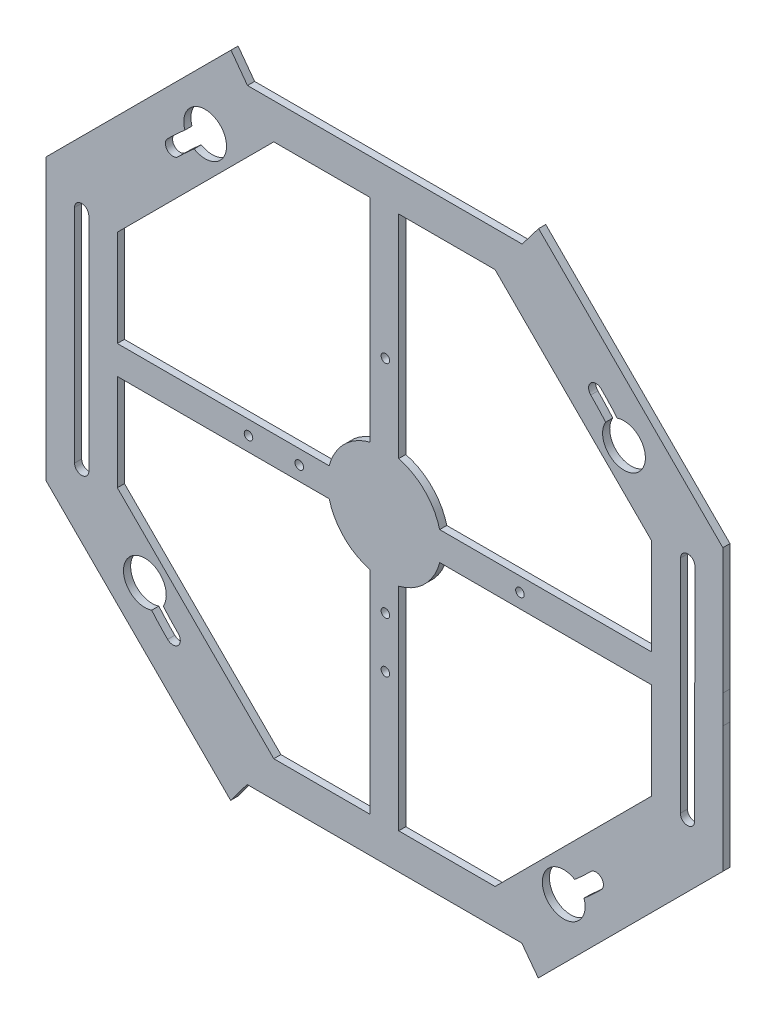
from build123d import *

# Parameters (mm, degrees)
BOSS_EXTRUDE1_DEPTH       = 3.175
SKETCH2_R                 = 3.302
BOSS_EXTRUDE2_DEPTH       = 3.175
BOSS_EXTRUDE3_DEPTH       = 3.175
BOSS_EXTRUDE4_DEPTH       = 3.175
SKETCH10_R                = 3.302
CUT_EXTRUDE2_DEPTH        = 3.175
BOSS_EXTRUDE6_DEPTH       = 3.175
F_6_CLEARANCE_HOLE1_D     = 3.7973
F_6_CLEARANCE_HOLE1_DEPTH = 25.4
F_6_CLEARANCE_HOLE1_TIP   = 1.140824014
CUT_EXTRUDE8_DEPTH        = 4.7625
SKETCH4_R                 = 25.4
BOSS_EXTRUDE7_DEPTH       = 3.175
CUT_EXTRUDE9_DEPTH        = 3.175
SKETCH19_R                = 9.525
CUT_EXTRUDE10_DEPTH       = 3.175
CUT_EXTRUDE12_DEPTH       = 4.175


with BuildPart() as part:
    # Sketch1 → Boss-Extrude1 (new body)
    with BuildSketch(Plane.XY):
        Polygon((-150.669615327, -62.417005507), (-62.404018861, -150.674994572), (62.417005507, -150.669615327), (150.674994572, -62.404018861), (150.669615327, 62.417005507), (62.404018861, 150.674994572), (-62.417005507, 150.669615327), (-150.674994572, 62.404018861), align=None)
        Polygon((-137.969842044, -57.155945955), (-57.144053939, -137.974767879), (57.155945955, -137.969842044), (137.974767879, -57.144053939), (137.969842044, 57.155945955), (57.144053939, 137.974767879), (-57.155945955, 137.969842044), (-137.974767879, 57.144053939), align=None, mode=Mode.SUBTRACT)
    extrude(amount=BOSS_EXTRUDE1_DEPTH)

    # Sketch2 → Boss-Extrude2 (add)
    with BuildSketch(Plane.XY.offset(3.175)):
        with BuildLine():
            Line((-104.300258744, 90.821465649), (-90.83045509, 104.292430334))
            ThreePointArc((-90.83045509, 104.292430334), (-90.829874575, 90.822046164), (-104.300258744, 90.821465649))
        make_face()
        with Locations((-94.197615746, 94.189497078)):
            Circle(SKETCH2_R, mode=Mode.SUBTRACT)
        with BuildLine():
            Line((104.292430334, 90.83045509), (90.821465649, 104.300258744))
            ThreePointArc((90.821465649, 104.300258744), (90.822046164, 90.829874575), (104.292430334, 90.83045509))
        make_face()
        with Locations((94.189497078, 94.197615746)):
            Circle(SKETCH2_R, mode=Mode.SUBTRACT)
        with BuildLine():
            Line((104.300258744, -90.821465649), (90.83045509, -104.292430334))
            ThreePointArc((90.83045509, -104.292430334), (90.829874575, -90.822046164), (104.300258744, -90.821465649))
        make_face()
        with Locations((94.197615746, -94.189497078)):
            Circle(SKETCH2_R, mode=Mode.SUBTRACT)
        with BuildLine():
            Line((-104.292430334, -90.83045509), (-90.821465649, -104.300258744))
            ThreePointArc((-90.821465649, -104.300258744), (-90.822046164, -90.829874575), (-104.292430334, -90.83045509))
        make_face()
        with Locations((-94.189497078, -94.197615746)):
            Circle(SKETCH2_R, mode=Mode.SUBTRACT)
    extrude(amount=-BOSS_EXTRUDE2_DEPTH)

    # Sketch5 → Boss-Extrude3 (add)
    with BuildSketch(Plane.XY.offset(3.175)):
        with BuildLine():
            Line((137.970389359, 44.455945967), (137.969842044, 57.155945955))
            Line((137.969842044, 57.155945955), (128.989198921, 66.135815058))
            ThreePointArc((128.989198921, 66.135815058), (126.236781441, 52.295360716), (137.970389359, 44.455945967))
        make_face()
        with BuildLine():
            Line((128.994898776, -66.124697061), (137.974767879, -57.144053939))
            Line((137.974767879, -57.144053939), (137.974220564, -44.44405395))
            ThreePointArc((137.974220564, -44.44405395), (126.241288378, -52.284480005), (128.994898776, -66.124697061))
        make_face()
        with BuildLine():
            Line((-137.969842044, -57.155945955), (-137.970389359, -44.455945967))
            ThreePointArc((-137.970389359, -44.455945967), (-126.236781441, -52.295360716), (-128.989198921, -66.135815058))
            Line((-128.989198921, -66.135815058), (-137.969842044, -57.155945955))
        make_face()
        with BuildLine():
            Line((-137.974220564, 44.44405395), (-137.974767879, 57.144053939))
            Line((-137.974767879, 57.144053939), (-128.994898776, 66.124697061))
            ThreePointArc((-128.994898776, 66.124697061), (-126.241288378, 52.284480005), (-137.974220564, 44.44405395))
        make_face()
    extrude(amount=-BOSS_EXTRUDE3_DEPTH)

    # Sketch9 → Boss-Extrude4 (add)
    with BuildSketch(Plane(origin=(0, 0, 0), x_dir=(-1, 0, 0), z_dir=(0, 0, -1))):
        Polygon((-57.144053939, 137.974767879), (-137.969842044, 57.155945955), (-137.974767879, -57.144053939), (-57.155945955, -137.969842044), (57.144053939, -137.974767879), (137.969842044, -57.155945955), (137.974767879, 57.144053939), (57.155945955, 137.969842044), align=None)
        Polygon((-49.254106555, 118.924427839), (-118.92018212, 49.264356627), (-118.924427839, -49.254106555), (-49.264356627, -118.92018212), (49.254106555, -118.924427839), (118.92018212, -49.264356627), (118.924427839, 49.254106555), (49.264356627, 118.92018212), align=None, mode=Mode.SUBTRACT)
    extrude(amount=-BOSS_EXTRUDE4_DEPTH)

    # Sketch10 → Cut-Extrude2 (cut)
    with BuildSketch(Plane.XY):
        with Locations((-94.197615746, 94.189497078)):
            Circle(SKETCH10_R)
        with Locations((94.189497078, 94.197615746)):
            Circle(SKETCH10_R)
        with Locations((-94.189497078, -94.197615746)):
            Circle(SKETCH10_R)
        with Locations((94.197615746, -94.189497078)):
            Circle(SKETCH10_R)
    extrude(amount=CUT_EXTRUDE2_DEPTH, mode=Mode.SUBTRACT)

    # Sketch12 → Boss-Extrude6 (add)
    with BuildSketch(Plane(origin=(0, 0, 0), x_dir=(-1, 0, 0), z_dir=(0, 0, -1))):
        Polygon((6.35, 150.672031572), (-6.35, 150.672031572), (-6.35, 6.35), (-150.672578887, 6.35), (-150.672578887, -6.35), (-6.35, -6.35), (-6.35, -150.672031572), (6.35, -150.672031572), (6.35, -6.35), (150.672578887, -6.35), (150.672578887, 6.35), (6.35, 6.35), align=None)
    extrude(amount=-BOSS_EXTRUDE6_DEPTH)

    # #6 Clearance Hole1
    with Locations(Plane(origin=(0, 0, 0), x_dir=(-1, 0, 0), z_dir=(0, 0, -1))):
        with Locations((-0.418811464, 60.325), (-0.418811464, -37.9222), (-0.418811464, -60.52312), (37.9222, 0), (60.52312, 0), (-60.325, 0)):
            Hole(F_6_CLEARANCE_HOLE1_D / 2, depth=F_6_CLEARANCE_HOLE1_DEPTH)
            with Locations((0, 0, -(F_6_CLEARANCE_HOLE1_DEPTH + F_6_CLEARANCE_HOLE1_TIP / 2))):  # 118° drill point
                Cone(0, F_6_CLEARANCE_HOLE1_D / 2, F_6_CLEARANCE_HOLE1_TIP, mode=Mode.SUBTRACT)

    # Sketch17 → Cut-Extrude8 (cut)
    with BuildSketch(Plane(origin=(0, 0, 0), x_dir=(-1, 0, 0), z_dir=(0, 0, -1))):
        Polygon((-73.383632924, 150.675467746), (-61.318869739, 134.799947792), (60.965361784, 134.794677872), (72.666366941, 150.669173624), align=None)
        Polygon((-61.147982987, -134.794670002), (61.136248536, -134.799939922), (73.018390518, -150.675452006), (-73.031609347, -150.669157884), align=None)
    extrude(amount=-CUT_EXTRUDE8_DEPTH, mode=Mode.SUBTRACT)

    # Sketch4 → Boss-Extrude7 (add)
    with BuildSketch(Plane.XY.offset(3.175)):
        Circle(SKETCH4_R)
    extrude(amount=-BOSS_EXTRUDE7_DEPTH)

    # Sketch18 → Cut-Extrude9 (cut)
    with BuildSketch(Plane.XY.offset(3.175)):
        with BuildLine():
            ThreePointArc((109.296804613, 81.790472735), (103.174175191, 89.389946316), (96.524263045, 96.532582958))
            ThreePointArc((96.524263045, 96.532582958), (91.854529866, 96.532381713), (91.854731111, 91.862648534))
            ThreePointArc((91.854731111, 91.862648534), (98.182941997, 85.065549572), (104.009378392, 77.833713966))
            ThreePointArc((104.009378392, 77.833713966), (108.631470887, 77.16838024), (109.296804613, 81.790472735))
        make_face()
        with BuildLine():
            ThreePointArc((81.790472735, -109.296804613), (89.389946316, -103.174175191), (96.532582958, -96.524263045))
            ThreePointArc((96.532582958, -96.524263045), (96.532381713, -91.854529866), (91.862648534, -91.854731111))
            ThreePointArc((91.862648534, -91.854731111), (85.065549572, -98.182941997), (77.833713966, -104.009378392))
            ThreePointArc((77.833713966, -104.009378392), (77.16838024, -108.631470887), (81.790472735, -109.296804613))
        make_face()
        with BuildLine():
            ThreePointArc((-109.296804613, -81.790472735), (-103.174175191, -89.389946316), (-96.524263045, -96.532582958))
            ThreePointArc((-96.524263045, -96.532582958), (-91.854529866, -96.532381713), (-91.854731111, -91.862648534))
            ThreePointArc((-91.854731111, -91.862648534), (-98.182941997, -85.065549572), (-104.009378392, -77.833713966))
            ThreePointArc((-104.009378392, -77.833713966), (-108.631470887, -77.16838024), (-109.296804613, -81.790472735))
        make_face()
        with BuildLine():
            ThreePointArc((-81.790472735, 109.296804613), (-89.389946316, 103.174175191), (-96.532582958, 96.524263045))
            ThreePointArc((-96.532582958, 96.524263045), (-96.532381713, 91.854529866), (-91.862648534, 91.854731111))
            ThreePointArc((-91.862648534, 91.854731111), (-85.065549572, 98.182941997), (-77.833713966, 104.009378392))
            ThreePointArc((-77.833713966, 104.009378392), (-77.16838024, 108.631470887), (-81.790472735, 109.296804613))
        make_face()
    extrude(amount=-CUT_EXTRUDE9_DEPTH, mode=Mode.SUBTRACT)

    # Sketch19 → Cut-Extrude10 (cut)
    with BuildSketch(Plane.XY.offset(3.175)):
        with Locations((-79.81209335, 106.653091503)):
            Circle(SKETCH19_R)
        with Locations((106.653091503, 79.81209335)):
            Circle(SKETCH19_R)
        with Locations((79.81209335, -106.653091503)):
            Circle(SKETCH19_R)
        with Locations((-106.653091503, -79.81209335)):
            Circle(SKETCH19_R)
    extrude(amount=-CUT_EXTRUDE10_DEPTH, mode=Mode.SUBTRACT)

    # Sketch22 → Cut-Extrude12 (cut, through all)
    with BuildSketch(Plane.XY.offset(3.175)):
        with BuildLine():
            Line((-137.97442785, 49.253969726), (-137.970182132, -49.264493456))
            ThreePointArc((-137.970182132, -49.264493456), (-134.795045306, -52.439356624), (-131.620182138, -49.264219798))
            Line((-131.620182138, -49.264219798), (-131.624427856, 49.254243384))
            ThreePointArc((-131.624427856, 49.254243384), (-134.799564682, 52.429106552), (-137.97442785, 49.253969726))
        make_face()
        with BuildLine():
            Line((131.869384327, 49.087223722), (131.740243733, -49.431154911))
            ThreePointArc((131.740243733, -49.431154911), (134.911079132, -52.610314057), (138.090238278, -49.439478658))
            Line((138.090238278, -49.439478658), (138.219378871, 49.078899975))
            ThreePointArc((138.219378871, 49.078899975), (135.048543473, 52.258059121), (131.869384327, 49.087223722))
        make_face()
    extrude(amount=-CUT_EXTRUDE12_DEPTH, mode=Mode.SUBTRACT)


solid = part.part
